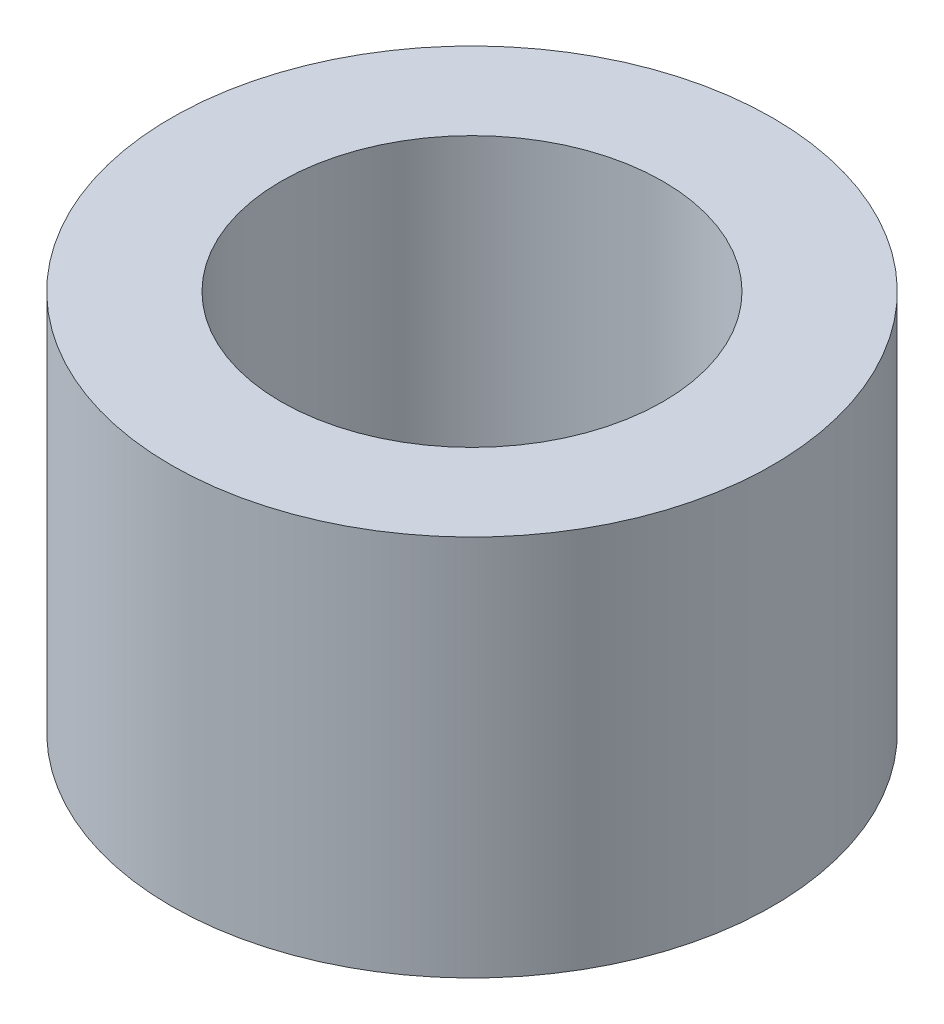
from build123d import *

# Parameters (mm, degrees)
SKETCH1_W = 1.15
SKETCH1_H = 4


with BuildPart() as part:
    # Sketch1 → Revolve1 (revolve)
    with BuildSketch(Plane.XY):
        with Locations((2.575, 2)):
            Rectangle(SKETCH1_W, SKETCH1_H)
    revolve(axis=Axis((0, 0, 0), (0, 1, 0)))


solid = part.part
